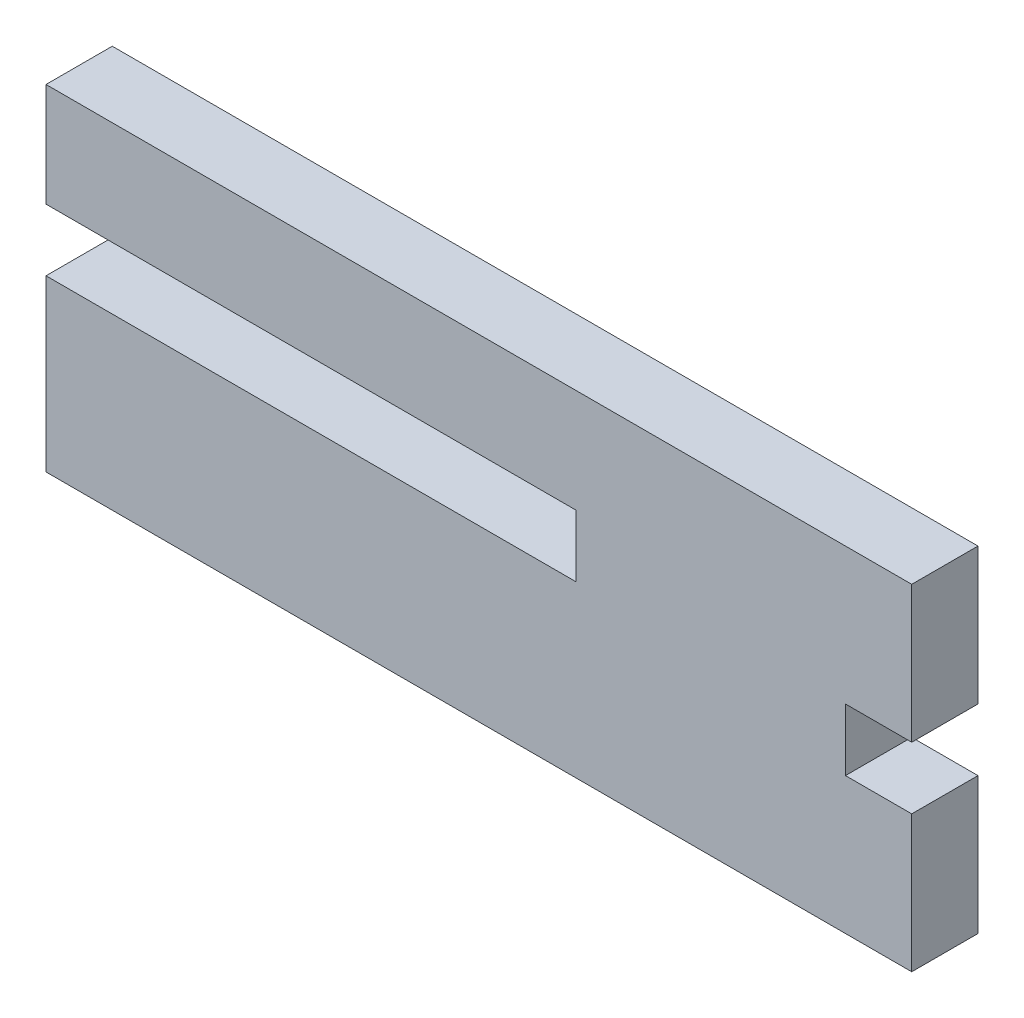
from build123d import *

# Parameters (mm, degrees)
BOSS_EXTRUDE1_DEPTH = 3.175


with BuildPart() as part:
    # Sketch1 → Boss-Extrude1 (new body)
    with BuildSketch(Plane.XY):
        Polygon((-0.1016, 15.9766), (-0.1016, 11.0109), (25.2984, 11.0109), (25.2984, 8.0391), (-0.1016, 8.0391), (-0.1016, -0.1016), (41.3766, -0.1016), (41.3766, 6.4516), (38.2016, 6.4516), (38.2016, 9.4234), (41.3766, 9.4234), (41.3766, 15.9766), align=None)
    extrude(amount=BOSS_EXTRUDE1_DEPTH)


solid = part.part
